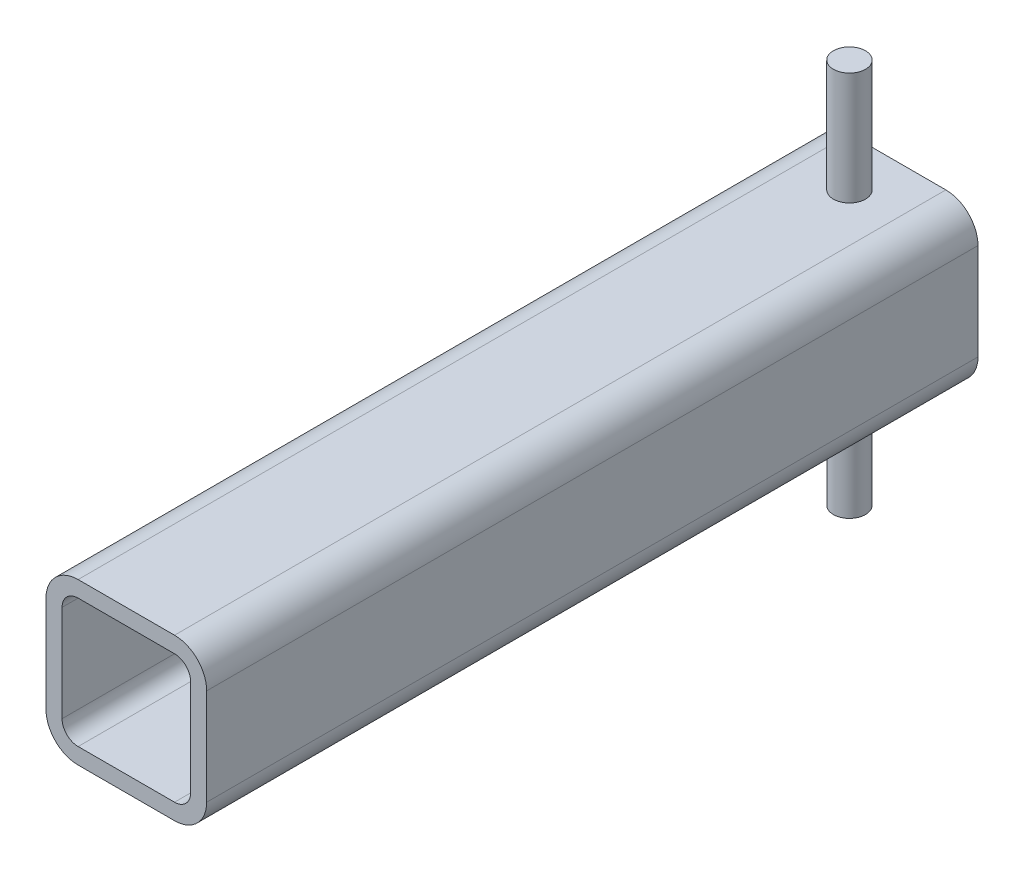
from build123d import *

# Parameters (mm, degrees)
BOSS_EXTRUDE1_DEPTH = 304.8
SKETCH3_R           = 6.35
BOSS_EXTRUDE2_DEPTH = 76.2


with BuildPart() as part:
    # Sketch1 → Boss-Extrude1 (new body)
    with BuildSketch(Plane.XY):
        with BuildLine():
            Line((19.05, 31.75), (-19.05, 31.75))
            ThreePointArc((-19.05, 31.75), (-28.030256121, 28.030256121), (-31.75, 19.05))
            Line((-31.75, 19.05), (-31.75, -19.05))
            ThreePointArc((-31.75, -19.05), (-28.030256121, -28.030256121), (-19.05, -31.75))
            Line((-19.05, -31.75), (19.05, -31.75))
            ThreePointArc((19.05, -31.75), (28.030256121, -28.030256121), (31.75, -19.05))
            Line((31.75, -19.05), (31.75, 19.05))
            ThreePointArc((31.75, 19.05), (28.030256121, 28.030256121), (19.05, 31.75))
        make_face()
        with BuildLine():
            ThreePointArc((-25.4, -19.05), (-23.540128061, -23.540128061), (-19.05, -25.4))
            Line((-19.05, -25.4), (19.05, -25.4))
            ThreePointArc((19.05, -25.4), (23.540128061, -23.540128061), (25.4, -19.05))
            Line((25.4, -19.05), (25.4, 19.05))
            ThreePointArc((25.4, 19.05), (23.540128061, 23.540128061), (19.05, 25.4))
            Line((19.05, 25.4), (-19.05, 25.4))
            ThreePointArc((-19.05, 25.4), (-23.540128061, 23.540128061), (-25.4, 19.05))
            Line((-25.4, 19.05), (-25.4, -19.05))
        make_face(mode=Mode.SUBTRACT)
    extrude(amount=BOSS_EXTRUDE1_DEPTH)

    # Sketch3 → Boss-Extrude2 (add, symmetric)
    with BuildSketch(Plane(origin=(0, 0, 0), x_dir=(1, 0, 0), z_dir=(0, 1, 0))):
        with Locations((0, -19.05)):
            Circle(SKETCH3_R)
    extrude(amount=BOSS_EXTRUDE2_DEPTH, both=True)


solid = part.part
